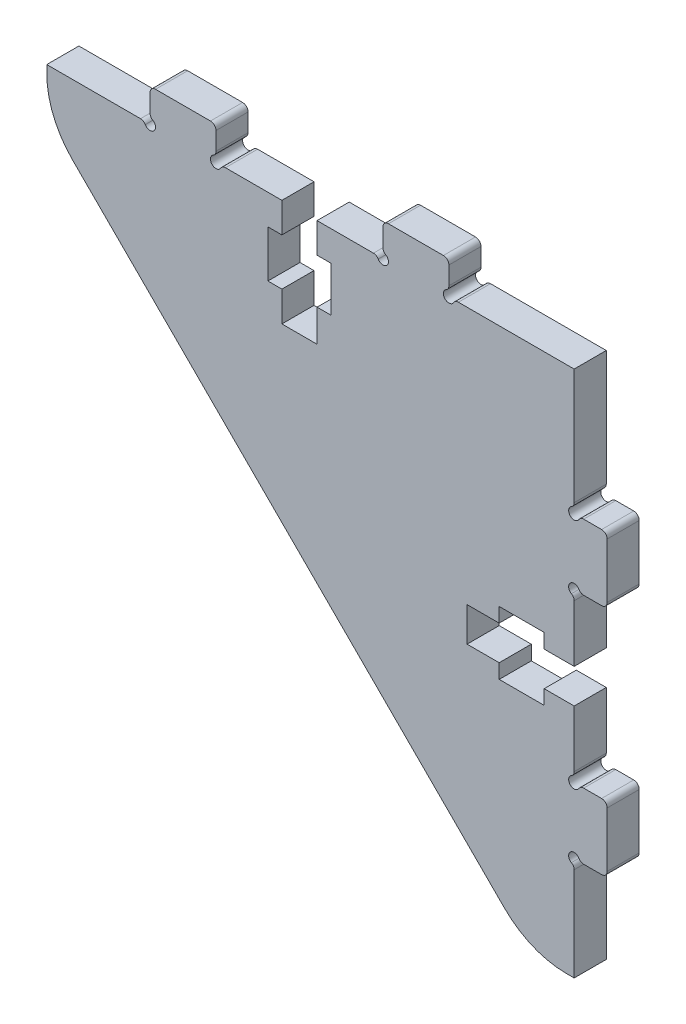
from build123d import *

# Parameters (mm, degrees)
BOSS_EXTRUDE1_DEPTH = 3


with BuildPart() as part:
    # Sketch1 → Boss-Extrude1 (new body)
    with BuildSketch(Plane.XY):
        with BuildLine():
            Line((278.748942769, 1025.68174137), (277.072289062, 1025.68174137))
            ThreePointArc((277.072289062, 1025.68174137), (276.81576773, 1025.613006812), (276.627980847, 1025.425220446))
            ThreePointArc((276.627980847, 1025.425220446), (275.820896535, 1025.31896689), (275.927149562, 1026.126051271))
            ThreePointArc((275.927149562, 1026.126051271), (276.114935991, 1026.313838161), (276.183670574, 1026.570359537))
            Line((276.183670574, 1026.570359537), (276.183670574, 1031.88000541))
            Line((276.183670574, 1031.88000541), (273.383670574, 1031.88000541))
            Line((273.383670574, 1031.88000541), (273.383670574, 1030.53000541))
            Line((273.383670574, 1030.53000541), (269.183670574, 1030.53000541))
            Line((269.183670574, 1030.53000541), (269.183670574, 1031.88000541))
            Line((269.183670574, 1031.88000541), (266.183670574, 1031.88000541))
            Line((266.183670574, 1031.88000541), (266.183670574, 1035.08000541))
            Line((266.183670574, 1035.08000541), (269.183670574, 1035.08000541))
            Line((269.183670574, 1035.08000541), (269.183670574, 1036.43000541))
            Line((269.183670574, 1036.43000541), (273.383670574, 1036.43000541))
            Line((273.383670574, 1036.43000541), (273.383670574, 1035.08000541))
            Line((273.383670574, 1035.08000541), (276.183670574, 1035.08000541))
            Line((276.183670574, 1035.08000541), (276.183670574, 1040.389649836))
            ThreePointArc((276.183670574, 1040.389649836), (276.114935781, 1040.646171575), (275.927148835, 1040.833958522))
            ThreePointArc((275.927148835, 1040.833958522), (275.820893173, 1041.641043417), (276.627978373, 1041.534790067))
            ThreePointArc((276.627978373, 1041.534790067), (276.815765346, 1041.347004134), (277.072286505, 1041.278269871))
            Line((277.072286505, 1041.278269871), (278.748941322, 1041.278269871))
            ThreePointArc((278.748941322, 1041.278269871), (279.111717845, 1041.428536827), (279.2619848, 1041.791313349))
            Line((279.2619848, 1041.791313349), (279.2619848, 1046.92174608))
            ThreePointArc((279.2619848, 1046.92174608), (279.111717845, 1047.284522602), (278.748941322, 1047.434789558))
            Line((278.748941322, 1047.434789558), (277.072287615, 1047.434789558))
            ThreePointArc((277.072287615, 1047.434789558), (276.815766284, 1047.366055), (276.6279794, 1047.178268634))
            ThreePointArc((276.6279794, 1047.178268634), (275.820895088, 1047.072015078), (275.927148115, 1047.879099459))
            ThreePointArc((275.927148115, 1047.879099459), (276.114934137, 1048.066885643), (276.183669127, 1048.323406094))
            Line((276.183669127, 1048.323406094), (276.183669127, 1059.132180233))
            Line((276.183669127, 1059.132180233), (265.374902832, 1059.132180233))
            ThreePointArc((265.374902832, 1059.132180233), (265.118381093, 1059.06344544), (264.930594147, 1058.875658494))
            ThreePointArc((264.930594147, 1058.875658494), (264.12351003, 1058.769403455), (264.229761575, 1059.576488032))
            ThreePointArc((264.229761575, 1059.576488032), (264.417547508, 1059.764275005), (264.486281771, 1060.020796163))
            Line((264.486281771, 1060.020796163), (264.486281771, 1061.697450981))
            ThreePointArc((264.486281771, 1061.697450981), (264.336014816, 1062.060227503), (263.973238293, 1062.210494459))
            Line((263.973238293, 1062.210494459), (258.842805647, 1062.210494459))
            ThreePointArc((258.842805647, 1062.210494459), (258.480029457, 1062.060227836), (258.329762168, 1061.697451923))
            Line((258.329762168, 1061.697451923), (258.329762168, 1060.020799457))
            ThreePointArc((258.329762168, 1060.020799457), (258.398497036, 1059.764277588), (258.586284167, 1059.576490622))
            ThreePointArc((258.586284167, 1059.576490622), (258.692539677, 1058.769406567), (257.885455039, 1058.875657641))
            ThreePointArc((257.885455039, 1058.875657641), (257.697667956, 1059.063443464), (257.441146757, 1059.132177578))
            Line((257.441146757, 1059.132177578), (252.173247105, 1059.132177578))
            Line((252.173247105, 1059.132177578), (252.173247105, 1056.332177578))
            Line((252.173247105, 1056.332177578), (253.481501818, 1056.332177578))
            Line((253.481501818, 1056.332177578), (253.481501818, 1052.132177578))
            Line((253.481501818, 1052.132177578), (252.173247105, 1052.132177578))
            Line((252.173247105, 1052.132177578), (252.173247105, 1049.132177578))
            Line((252.173247105, 1049.132177578), (248.889756531, 1049.132177578))
            Line((248.889756531, 1049.132177578), (248.889756531, 1051.949568882))
            Line((248.889756531, 1051.949568882), (247.581501818, 1051.949568882))
            Line((247.581501818, 1051.949568882), (247.581501818, 1056.332177578))
            Line((247.581501818, 1056.332177578), (248.889756531, 1056.332177578))
            Line((248.889756531, 1056.332177578), (248.889756531, 1059.132177578))
            Line((248.889756531, 1059.132177578), (243.621854827, 1059.132177578))
            ThreePointArc((243.621854827, 1059.132177578), (243.365333088, 1059.063442785), (243.177546141, 1058.875655838))
            ThreePointArc((243.177546141, 1058.875655838), (242.370461246, 1058.769400177), (242.476714596, 1059.576485377))
            ThreePointArc((242.476714596, 1059.576485377), (242.664500529, 1059.764272349), (242.733234792, 1060.020793508))
            Line((242.733234792, 1060.020793508), (242.733234792, 1061.697448325))
            ThreePointArc((242.733234792, 1061.697448325), (242.582967836, 1062.060224848), (242.220191314, 1062.210491804))
            Line((242.220191314, 1062.210491804), (237.089758668, 1062.210491804))
            ThreePointArc((237.089758668, 1062.210491804), (236.726982478, 1062.060225181), (236.576715189, 1061.697449267))
            Line((236.576715189, 1061.697449267), (236.576715189, 1060.020796683))
            ThreePointArc((236.576715189, 1060.020796683), (236.645450027, 1059.764274865), (236.833237085, 1059.576487907))
            ThreePointArc((236.833237085, 1059.576487907), (236.939492407, 1058.769403827), (236.132407793, 1058.875655089))
            ThreePointArc((236.132407793, 1058.875655089), (235.944620754, 1059.063440956), (235.688099571, 1059.132175129))
            Line((235.688099571, 1059.132175129), (226.93149811, 1059.132175129))
            Line((226.93149811, 1059.132175129), (226.93149811, 1058.427981397))
            ThreePointArc((226.93149811, 1058.427981397), (227.55634793, 1055.286649403), (229.335769658, 1052.623556781))
            Line((229.335769658, 1052.623556781), (269.675051729, 1012.284272653))
            ThreePointArc((269.675051729, 1012.284272653), (272.338145025, 1010.504850709), (275.479477777, 1009.880001213))
            Line((275.479477777, 1009.880001213), (276.183670574, 1009.880001213))
            Line((276.183670574, 1009.880001213), (276.183670574, 1018.636602674))
            ThreePointArc((276.183670574, 1018.636602674), (276.114935781, 1018.893124413), (275.927148835, 1019.08091136))
            ThreePointArc((275.927148835, 1019.08091136), (275.820893173, 1019.887996255), (276.627978373, 1019.781742905))
            ThreePointArc((276.627978373, 1019.781742905), (276.815765346, 1019.593956972), (277.072286504, 1019.525222709))
            Line((277.072286504, 1019.525222709), (278.748941322, 1019.525222709))
            ThreePointArc((278.748941322, 1019.525222709), (279.111717844, 1019.675489665), (279.2619848, 1020.038266187))
            Line((279.2619848, 1020.038266187), (279.2619848, 1025.168697892))
            ThreePointArc((279.2619848, 1025.168697892), (279.111718356, 1025.531473903), (278.748942769, 1025.68174137))
        make_face()
    extrude(amount=BOSS_EXTRUDE1_DEPTH)


solid = part.part
